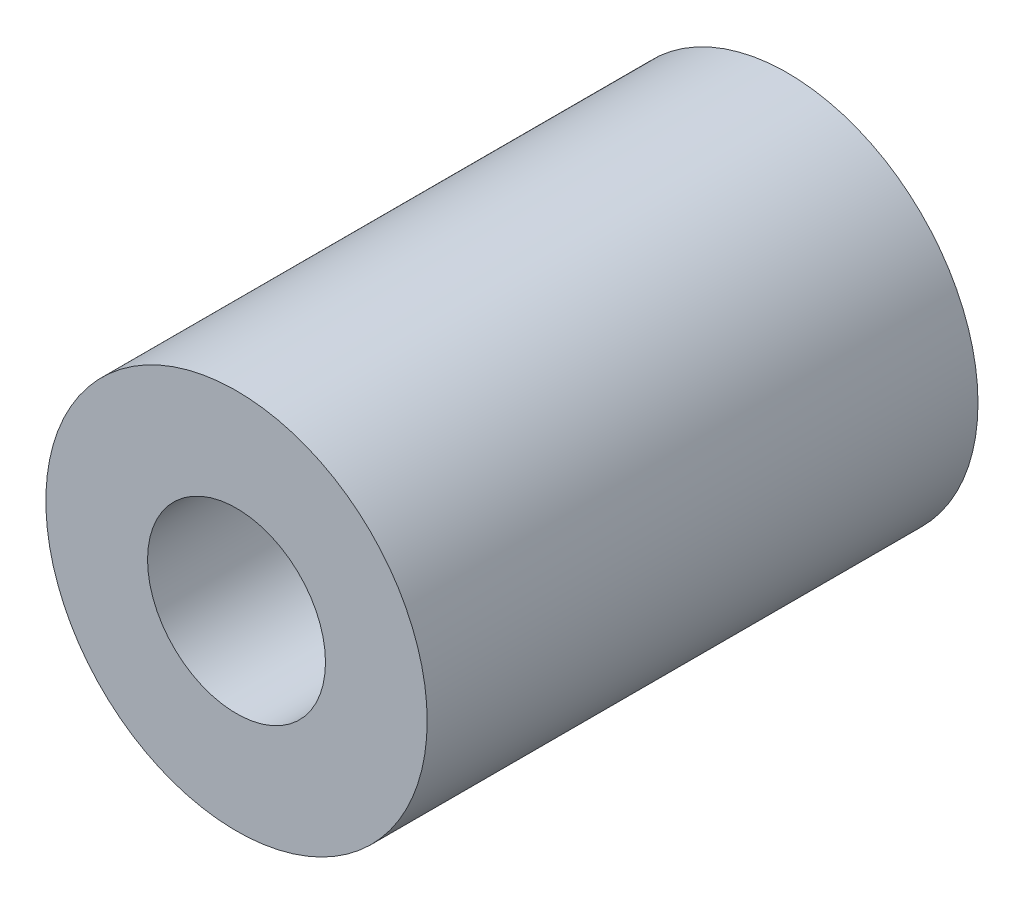
from build123d import *

# Parameters (mm, degrees)
CROQUIS1_R              = 9
CROQUIS1_R_2            = 4.2
SALIENTE_EXTRUIR1_DEPTH = 26


with BuildPart() as part:
    # Croquis1 → Saliente-Extruir1 (new body)
    with BuildSketch(Plane.XY):
        Circle(CROQUIS1_R)
        Circle(CROQUIS1_R_2, mode=Mode.SUBTRACT)
    extrude(amount=SALIENTE_EXTRUIR1_DEPTH)


solid = part.part
